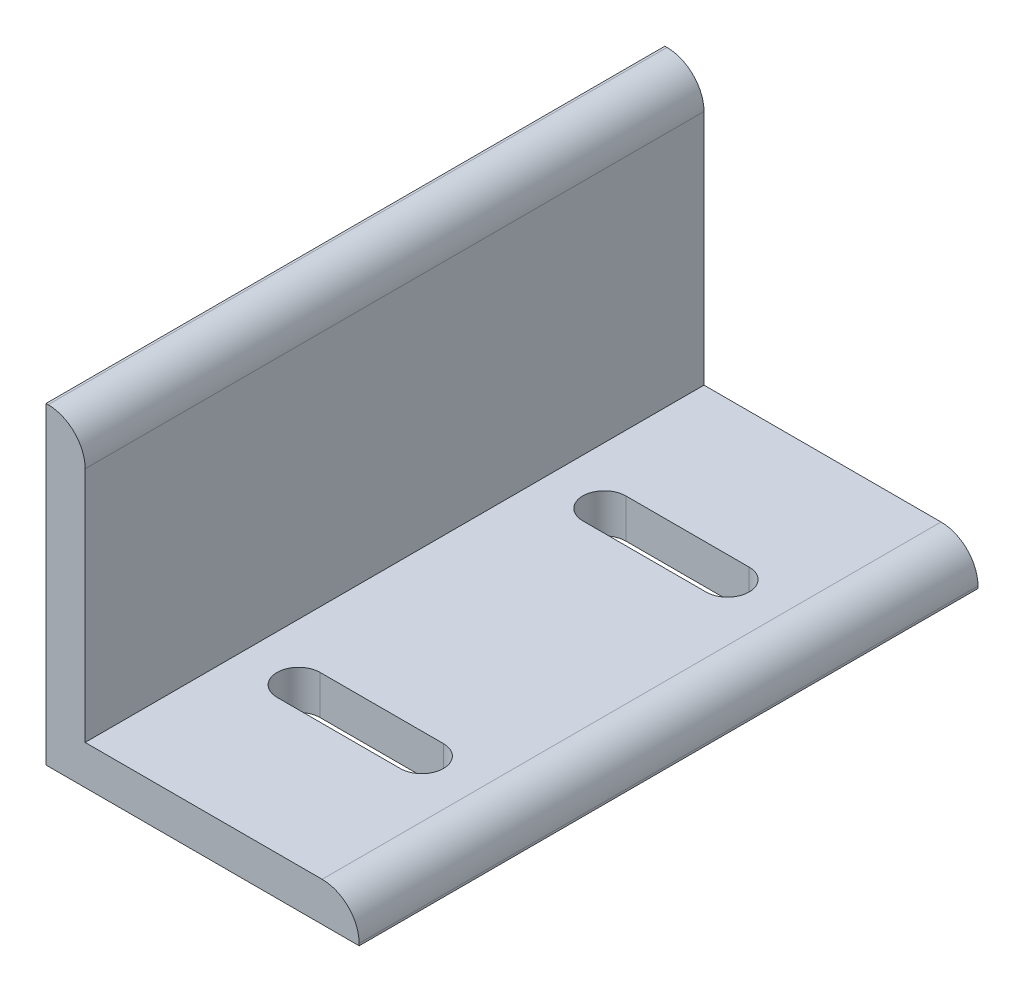
from build123d import *

# Parameters (mm, degrees)
BOSS_EXTRUDE1_DEPTH = 100.4
CUT_EXTRUDE1_DEPTH  = 10


with BuildPart() as part:
    # Sketch1 → Boss-Extrude1 (new body)
    with BuildSketch(Plane.XY):
        with BuildLine():
            Line((44.8, 6.35), (12.35, 6.35))
            Line((12.35, 6.35), (6.35, 6.35))
            Line((6.35, 6.35), (6.35, 44.8))
            ThreePointArc((6.35, 44.8), (4.592640687, 49.042640687), (0.35, 50.8))
            Line((0.35, 50.8), (0, 50.8))
            Line((0, 50.8), (0, 6.35))
            Line((0, 6.35), (0, 0))
            Line((0, 0), (6.35, 0))
            Line((6.35, 0), (50.8, 0))
            Line((50.8, 0), (50.8, 0.35))
            ThreePointArc((50.8, 0.35), (49.042640687, 4.592640687), (44.8, 6.35))
        make_face()
    extrude(amount=BOSS_EXTRUDE1_DEPTH)

    # Sketch2 → Cut-Extrude1 (cut)
    with BuildSketch(Plane(origin=(0, 6.35, 0), x_dir=(1, 0, 0), z_dir=(0, 1, 0))):
        with BuildLine():
            Line((15.575, -21.9), (35.575, -21.9))
            ThreePointArc((35.575, -21.9), (39.075, -25.4), (35.575, -28.9))
            Line((35.575, -28.9), (15.575, -28.9))
            ThreePointArc((15.575, -28.9), (12.075, -25.4), (15.575, -21.9))
        make_face()
        with BuildLine():
            Line((15.575, -78.5), (35.575, -78.5))
            ThreePointArc((35.575, -78.5), (39.075, -75), (35.575, -71.5))
            Line((35.575, -71.5), (15.575, -71.5))
            ThreePointArc((15.575, -71.5), (12.075, -75), (15.575, -78.5))
        make_face()
    extrude(amount=-CUT_EXTRUDE1_DEPTH, mode=Mode.SUBTRACT)


solid = part.part
